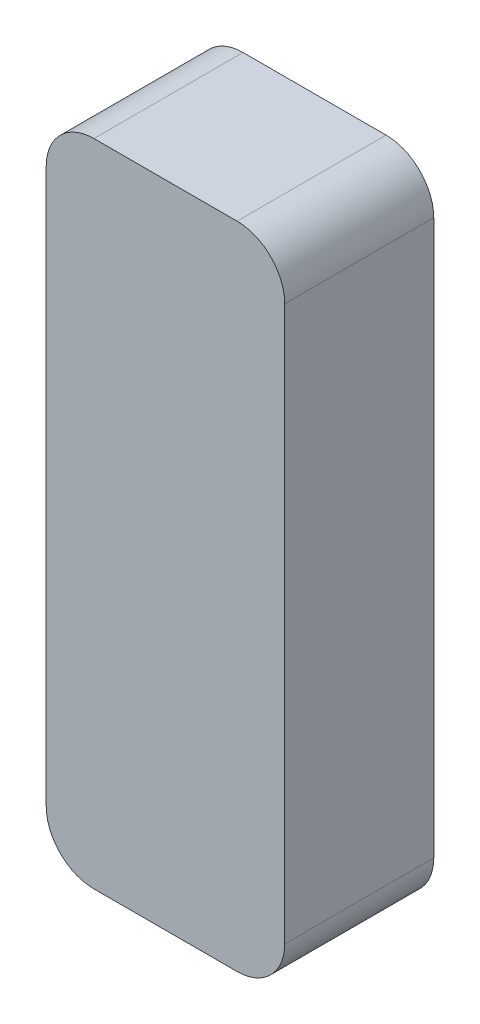
from build123d import *

# Parameters (mm, degrees)
SKETCH1_W           = 40
SKETCH1_H           = 109
BOSS_EXTRUDE1_DEPTH = 25
FILLET1_R           = 8


with BuildPart() as part:
    # Sketch1 → Boss-Extrude1 (new body)
    with BuildSketch(Plane.XY):
        Rectangle(SKETCH1_W, SKETCH1_H)
    extrude(amount=BOSS_EXTRUDE1_DEPTH)

    # Fillet1
    fillet1_edges = [part.edges().sort_by_distance(p)[0] for p in [
        (20, -54.5, 12.5),
        (-20, -54.5, 12.5),
        (-20, 54.5, 12.5),
        (20, 54.5, 12.5),
    ]]
    fillet(fillet1_edges, radius=FILLET1_R)


solid = part.part
